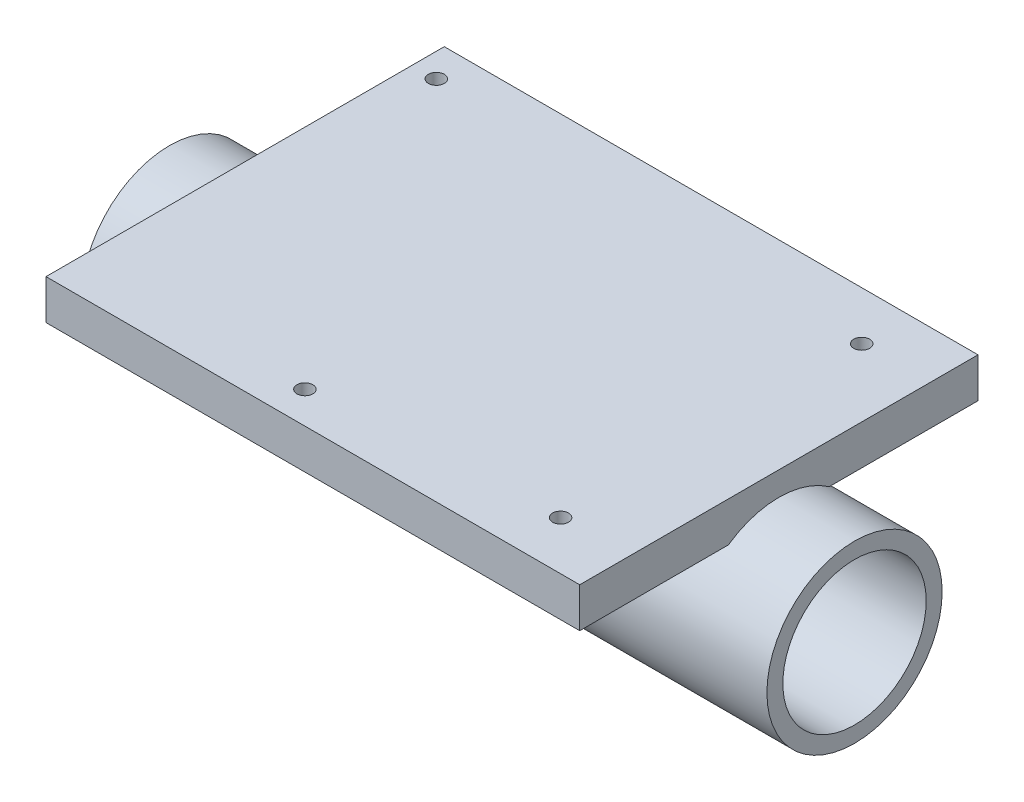
from build123d import *

# Parameters (mm, degrees)
SKETCH_1_W          = 67
SKETCH_1_H          = 50
EXTRUDE_1_DEPTH     = 5
SKETCH_2_R          = 1
CUT_EXTRUDE_1_DEPTH = 6
SKETCH_4_R          = 11
SKETCH_4_R_2        = 9
EXTRUDE_2_DEPTH     = 43


with BuildPart() as part:
    # 草图1 → 凸台-拉伸1 (new body)
    with BuildSketch(Plane(origin=(0, 0, 0), x_dir=(1, 0, 0), z_dir=(0, 1, 0))):
        Rectangle(SKETCH_1_W, SKETCH_1_H)
    extrude(amount=EXTRUDE_1_DEPTH)

    # 草图2 → 切除-拉伸1 (cut, through all)
    with BuildSketch(Plane(origin=(0, 5, 0), x_dir=(1, 0, 0), z_dir=(0, 1, 0))):
        with Locations((-5, -21)):
            Circle(SKETCH_2_R)
        with Locations((25, -18.9)):
            Circle(SKETCH_2_R)
        with Locations((25, 18.9)):
            Circle(SKETCH_2_R)
        with Locations((-30.5, 21)):
            Circle(SKETCH_2_R)
    extrude(amount=-CUT_EXTRUDE_1_DEPTH, mode=Mode.SUBTRACT)


with BuildPart() as body_2:
    # 草图4 → 凸台-拉伸2 (new body, symmetric)
    with BuildSketch(Plane(origin=(0, 0, 0), x_dir=(0, 0, -1), z_dir=(1, 0, 0))):
        with Locations((0, -9)):
            Circle(SKETCH_4_R)
        with Locations((0, -9)):
            Circle(SKETCH_4_R_2, mode=Mode.SUBTRACT)
    extrude(amount=EXTRUDE_2_DEPTH, both=True)


solid = Compound([part.part, body_2.part])
